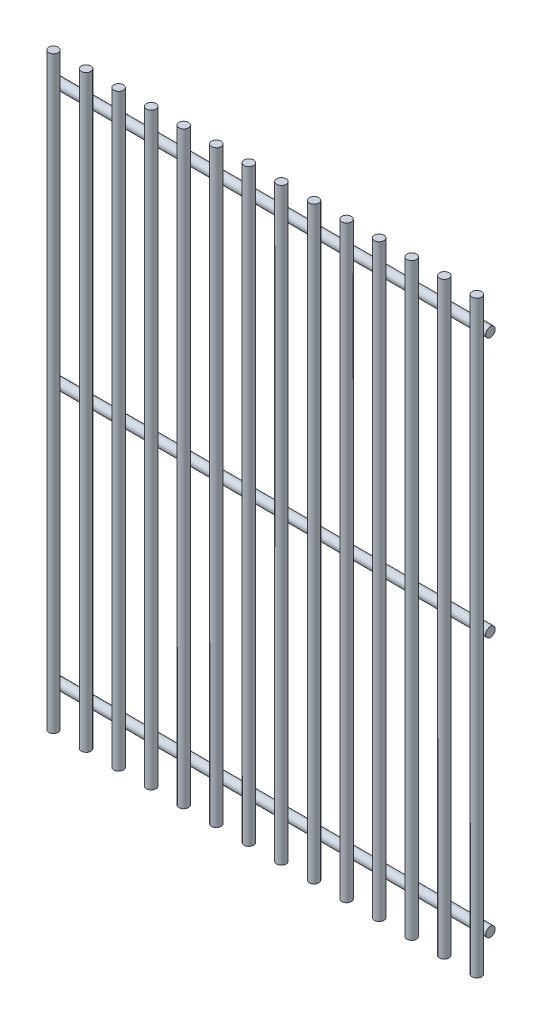
from build123d import *

# Parameters (mm, degrees)
SKETCH1_R           = 3.5
BOSS_EXTRUDE1_DEPTH = 215.9
LPATTERN1_COUNT     = 14
LPATTERN1_PITCH     = 23.884615387
SKETCH2_R           = 3.5
BOSS_EXTRUDE2_DEPTH = 158.75


with BuildPart() as part:
    # Sketch1 → Boss-Extrude1 (new body, symmetric)
    with BuildSketch(Plane(origin=(0, 0, 0), x_dir=(1, 0, 0), z_dir=(0, 1, 0))):
        with Locations((-155.25, -3.5)):
            Circle(SKETCH1_R)
    extrude(amount=BOSS_EXTRUDE1_DEPTH, both=True)


with BuildPart() as lpattern1_1:
    # LPattern1: pattern copy
    add(part.part.moved(Location(Vector(1, 0, 0) * (1 * LPATTERN1_PITCH))))


with BuildPart() as lpattern1_2:
    # LPattern1: pattern copy
    add(part.part.moved(Location(Vector(1, 0, 0) * (2 * LPATTERN1_PITCH))))


with BuildPart() as lpattern1_3:
    # LPattern1: pattern copy
    add(part.part.moved(Location(Vector(1, 0, 0) * (3 * LPATTERN1_PITCH))))


with BuildPart() as lpattern1_4:
    # LPattern1: pattern copy
    add(part.part.moved(Location(Vector(1, 0, 0) * (4 * LPATTERN1_PITCH))))


with BuildPart() as lpattern1_5:
    # LPattern1: pattern copy
    add(part.part.moved(Location(Vector(1, 0, 0) * (5 * LPATTERN1_PITCH))))


with BuildPart() as lpattern1_6:
    # LPattern1: pattern copy
    add(part.part.moved(Location(Vector(1, 0, 0) * (6 * LPATTERN1_PITCH))))


with BuildPart() as lpattern1_7:
    # LPattern1: pattern copy
    add(part.part.moved(Location(Vector(1, 0, 0) * (7 * LPATTERN1_PITCH))))


with BuildPart() as lpattern1_8:
    # LPattern1: pattern copy
    add(part.part.moved(Location(Vector(1, 0, 0) * (8 * LPATTERN1_PITCH))))


with BuildPart() as lpattern1_9:
    # LPattern1: pattern copy
    add(part.part.moved(Location(Vector(1, 0, 0) * (9 * LPATTERN1_PITCH))))


with BuildPart() as lpattern1_10:
    # LPattern1: pattern copy
    add(part.part.moved(Location(Vector(1, 0, 0) * (10 * LPATTERN1_PITCH))))


with BuildPart() as lpattern1_11:
    # LPattern1: pattern copy
    add(part.part.moved(Location(Vector(1, 0, 0) * (11 * LPATTERN1_PITCH))))


with BuildPart() as lpattern1_12:
    # LPattern1: pattern copy
    add(part.part.moved(Location(Vector(1, 0, 0) * (12 * LPATTERN1_PITCH))))


with BuildPart() as lpattern1_13:
    # LPattern1: pattern copy
    add(part.part.moved(Location(Vector(1, 0, 0) * (13 * LPATTERN1_PITCH))))


with BuildPart() as part_1:
    add(part.part)

    add(lpattern1_1.part)  # Boss-Extrude2 merges LPattern1_1

    add(lpattern1_2.part)  # Boss-Extrude2 merges LPattern1_2

    add(lpattern1_3.part)  # Boss-Extrude2 merges LPattern1_3

    add(lpattern1_4.part)  # Boss-Extrude2 merges LPattern1_4

    add(lpattern1_5.part)  # Boss-Extrude2 merges LPattern1_5

    add(lpattern1_6.part)  # Boss-Extrude2 merges LPattern1_6

    add(lpattern1_7.part)  # Boss-Extrude2 merges LPattern1_7

    add(lpattern1_8.part)  # Boss-Extrude2 merges LPattern1_8

    add(lpattern1_9.part)  # Boss-Extrude2 merges LPattern1_9

    add(lpattern1_10.part)  # Boss-Extrude2 merges LPattern1_10

    add(lpattern1_11.part)  # Boss-Extrude2 merges LPattern1_11

    add(lpattern1_12.part)  # Boss-Extrude2 merges LPattern1_12

    add(lpattern1_13.part)  # Boss-Extrude2 merges LPattern1_13
    # Sketch2 → Boss-Extrude2 (add, symmetric)
    with BuildSketch(Plane(origin=(0, 0, 0), x_dir=(0, 0, -1), z_dir=(1, 0, 0))):
        with Locations((3, -190.5)):
            Circle(SKETCH2_R)
        with Locations((3, 190.5)):
            Circle(SKETCH2_R)
        with Locations((3, 0)):
            Circle(SKETCH2_R)
    extrude(amount=BOSS_EXTRUDE2_DEPTH, both=True)


solid = part_1.part
